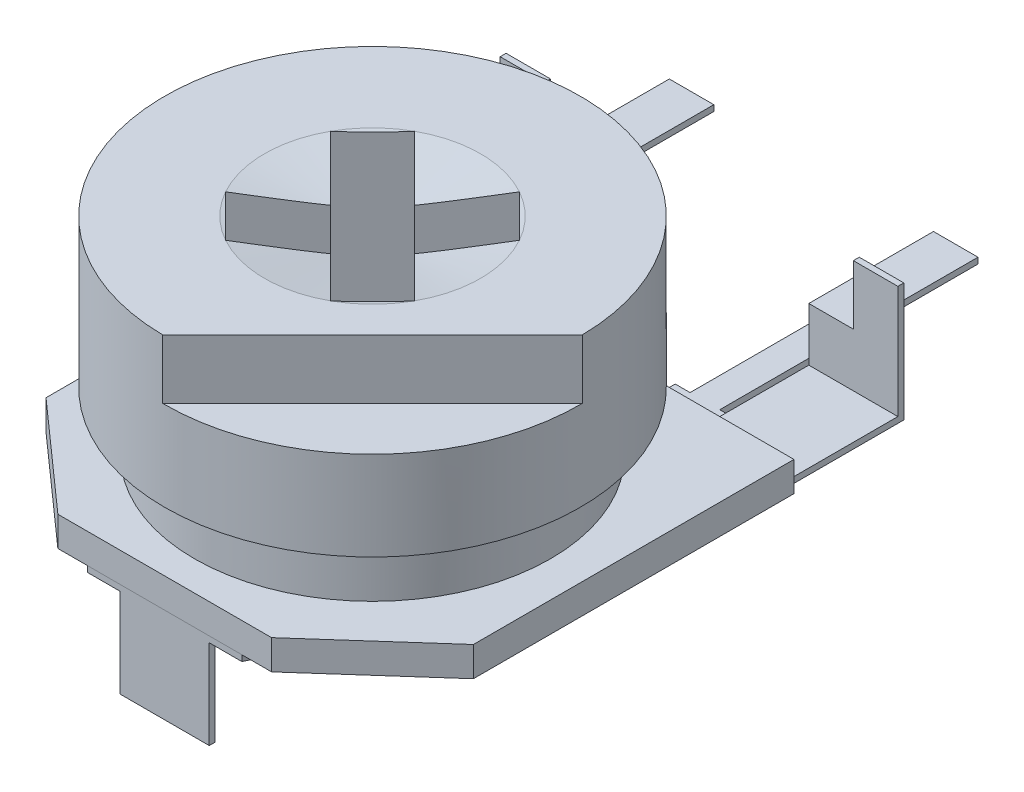
from build123d import *

# Parameters (mm, degrees)
SKETCH1_R              = 3.5
BOSS_EXTRUDE1_DEPTH    = 2.5
CUT_EXTRUDE1_DEPTH     = 1
SKETCH4_R              = 3
BOSS_EXTRUDE2_DEPTH    = 1
FILLET1_R              = 0.25
SKETCH5_R              = 1
BOSS_EXTRUDE3_DEPTH    = 0.5
SKETCH6_R              = 1
BOSS_EXTRUDE4_DEPTH    = 0.1
SKETCH6_W              = 1.5
SKETCH6_H              = 3.5
BOSS_EXTRUDE4_2_DEPTH  = 0.1
BOSS_EXTRUDE4_3_DEPTH  = 0.1
SKETCH7_W              = 1.5
SKETCH7_H              = 0.1
SKETCH7_W_2            = 2
SKETCH7_H_2            = 1
BOSS_EXTRUDE5_DEPTH    = 1.5
BOSS_EXTRUDE6_DEPTH    = 0.1
SKETCH9_W              = 0.75
SKETCH9_H              = 0.1
BOSS_EXTRUDE7_DEPTH    = 2
SKETCH11_W             = 1
SKETCH11_H             = 0.1
BOSS_EXTRUDE8_DEPTH    = 2.1
SKETCH12_W             = 0.5
SKETCH12_H             = 0.1
BOSS_EXTRUDE9_DEPTH    = 2
BOSS_EXTRUDE10_DEPTH   = 0.8
BOSS_EXTRUDE10_2_DEPTH = 0.8


with BuildPart() as part:
    # Sketch1 → Boss-Extrude1 (new body)
    with BuildSketch(Plane(origin=(0, 0, 0), x_dir=(1, 0, 0), z_dir=(0, 1, 0))):
        with Locations(Location((0, 0, 0), (0, 0, 270))):
            Circle(SKETCH1_R)
        Polygon((0.883883476, 1.590990258), (0, 0.707106781), (-0.883883476, 1.590990258), (-1.590990258, 0.883883476), (-0.707106781, 0), (-1.590990258, -0.883883476), (-0.883883476, -1.590990258), (0, -0.707106781), (0.883883476, -1.590990258), (1.590990258, -0.883883476), (0.707106781, 0), (1.590990258, 0.883883476), align=None, mode=Mode.SUBTRACT)
    extrude(amount=-BOSS_EXTRUDE1_DEPTH)

    # Sketch2 → Cut-Extrude1 (cut)
    with BuildSketch(Plane(origin=(0, 0, 0), x_dir=(1, 0, 0), z_dir=(0, 1, 0))):
        with BuildLine():
            Line((3.499817761, 0.035716145), (-0.035716145, -3.499817761))
            ThreePointArc((-0.035716145, -3.499817761), (2.474873734, -2.474873734), (3.499817761, 0.035716145))
        make_face()
    extrude(amount=-CUT_EXTRUDE1_DEPTH, mode=Mode.SUBTRACT)

    # Cut-Extrude2 cone 1 section (through the dimple's axis) → Cut-Extrude2 (revolve, cut)
    with BuildSketch(Plane(origin=(0, 0, 0), x_dir=(0, 0, 1), z_dir=(1, 0, 0))):
        Polygon((0, 0), (1.820027472, 0), (0, 0.320919949), align=None)
    revolve(axis=Axis((0, 0, 0), (0, -1, 0)), mode=Mode.SUBTRACT)

    # Sketch4 → Boss-Extrude2 (add)
    with BuildSketch(Plane.XZ.offset(2.5)):
        with Locations(Location((0, 0, 0), (0, 0, 270))):
            Circle(SKETCH4_R)
    extrude(amount=BOSS_EXTRUDE2_DEPTH)

    # Fillet1
    fillet1_edges = [part.edges().sort_by_distance(p)[0] for p in [
        (0, -2.5, 3),
    ]]
    fillet(fillet1_edges, radius=FILLET1_R)


with BuildPart() as body_2:
    # Sketch5 → Boss-Extrude3 (new body)
    with BuildSketch(Plane.XZ.offset(3.5)):
        Polygon((1.8, 3.5), (3.6, 1.9), (3.6, -3.5), (-3.6, -3.5), (-3.6, 1.9), (-1.8, 3.5), align=None)
        with Locations(Location((0, 0, 0), (0, 0, 270))):
            Circle(SKETCH5_R, mode=Mode.SUBTRACT)
    extrude(amount=BOSS_EXTRUDE3_DEPTH)


with BuildPart() as body_3:
    # Sketch6 → Boss-Extrude4 (new body)
    with BuildSketch(Plane.XZ.offset(4)):
        Polygon((-1.3, 3.5), (-2, 2), (-2, -0.5), (-1, -1.618033989), (-1, -3.5), (1, -3.5), (1, -1.618033989), (2, -0.5), (2, 2), (1.3, 3.5), align=None)
        with Locations(Location((0, 0, 0), (0, 0, 270))):
            Circle(SKETCH6_R, mode=Mode.SUBTRACT)
    extrude(amount=BOSS_EXTRUDE4_DEPTH)

    # Sketch7 → Boss-Extrude5 (add)
    with BuildSketch(Plane.XZ.offset(4.1)):
        with Locations((0, 3.45)):
            Rectangle(SKETCH7_W, SKETCH7_H)
        with Locations((0, -3)):
            Rectangle(SKETCH7_W_2, SKETCH7_H_2)
    extrude(amount=BOSS_EXTRUDE5_DEPTH)

    # Sketch11 → Boss-Extrude8 (add)
    with BuildSketch(Plane(origin=(0, 0, -3.5), x_dir=(-1, 0, 0), z_dir=(0, 0, -1))):
        with Locations((0, -5.55)):
            Rectangle(SKETCH11_W, SKETCH11_H)
    extrude(amount=BOSS_EXTRUDE8_DEPTH)

    # Sketch12 → Boss-Extrude9 (add)
    with BuildSketch(Plane(origin=(0, 0, -5.6), x_dir=(-1, 0, 0), z_dir=(0, 0, -1))):
        with Locations((0, -5.55)):
            Rectangle(SKETCH12_W, SKETCH12_H)
    extrude(amount=BOSS_EXTRUDE9_DEPTH)


with BuildPart() as body_4:
    # Sketch6 → Boss-Extrude4 2 (new body)
    with BuildSketch(Plane.XZ.offset(4)):
        with Locations((-2.6, -3.75)):
            Rectangle(SKETCH6_W, SKETCH6_H)
    extrude(amount=BOSS_EXTRUDE4_2_DEPTH)



with BuildPart() as body_5:
    # Sketch6 → Boss-Extrude4 3 (new body)
    with BuildSketch(Plane.XZ.offset(4)):
        with Locations((2.6, -3.75)):
            Rectangle(SKETCH6_W, SKETCH6_H)
    extrude(amount=BOSS_EXTRUDE4_3_DEPTH)


with BuildPart() as body_4_1:
    add(body_4.part)

    add(body_5.part)  # Boss-Extrude6 merges body 5
    # Sketch8 → Boss-Extrude6 (add)
    with BuildSketch(Plane(origin=(0, 0, -5.5), x_dir=(-1, 0, 0), z_dir=(0, 0, -1))):
        Polygon((-3.35, -4.1), (-1.85, -4.1), (-1.85, -3.1), (-2.6, -3.1), (-2.6, -2.1), (-3.35, -2.1), align=None)
        Polygon((3.35, -4.1), (1.85, -4.1), (1.85, -3.1), (2.6, -3.1), (2.6, -2.1), (3.35, -2.1), align=None)
    extrude(amount=BOSS_EXTRUDE6_DEPTH)

    # Sketch9 → Boss-Extrude7 (add)
    with BuildSketch(Plane(origin=(0, 0, -5.6), x_dir=(-1, 0, 0), z_dir=(0, 0, -1))):
        with Locations((-2.225, -3.15)):
            Rectangle(SKETCH9_W, SKETCH9_H)
        with Locations((2.225, -3.15)):
            Rectangle(SKETCH9_W, SKETCH9_H)
    extrude(amount=BOSS_EXTRUDE7_DEPTH)


with BuildPart() as body_5_2:
    # Sketch13 → Boss-Extrude10 (new body)
    with BuildSketch(Plane.XZ.offset(3.5)):
        with BuildLine():
            Line((-0.507876502, -0.861429892), (0.861429892, 0.507876502))
            ThreePointArc((0.861429892, 0.507876502), (0.707106781, -0.707106781), (-0.507876502, -0.861429892))
        make_face()
    extrude(amount=BOSS_EXTRUDE10_DEPTH)


with BuildPart() as body_6:
    # Sketch13 → Boss-Extrude10 2 (new body)
    with BuildSketch(Plane.XZ.offset(3.5)):
        with BuildLine():
            Line((-0.861429892, -0.507876502), (0.507876502, 0.861429892))
            ThreePointArc((0.507876502, 0.861429892), (-0.707106781, 0.707106781), (-0.861429892, -0.507876502))
        make_face()
    extrude(amount=BOSS_EXTRUDE10_2_DEPTH)


solid = Compound([part.part, body_2.part, body_3.part, body_4_1.part, body_5_2.part, body_6.part])
